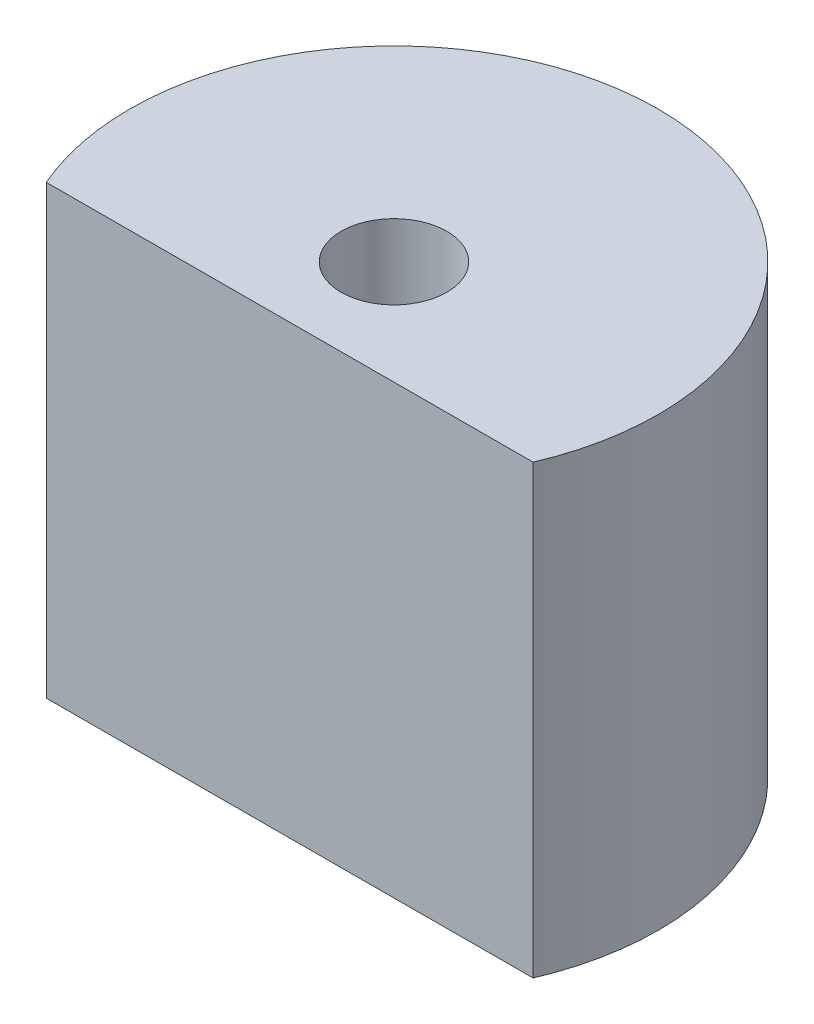
from build123d import *

# Parameters (mm, degrees)
SKETCH1_R               = 7.9375
SKETCH1_R_2             = 1.5875
BOSS_EXTRUDE1_DEPTH     = 13.4112
CUT_EXTRUDE1_DEPTH      = 18.489085109
CUT_EXTRUDE1_DEPTH_BACK = 18.489085109


with BuildPart() as part:
    # Sketch1 → Boss-Extrude1 (new body)
    with BuildSketch(Plane(origin=(0, 0, 0), x_dir=(1, 0, 0), z_dir=(0, 1, 0))):
        Circle(SKETCH1_R)
        Circle(SKETCH1_R_2, mode=Mode.SUBTRACT)
    extrude(amount=BOSS_EXTRUDE1_DEPTH)

    # Sketch2 → Cut-Extrude1 (cut, two sides: drawn at the far end of the back side and taken through both)
    with BuildSketch(Plane.XZ.offset(-CUT_EXTRUDE1_DEPTH_BACK)):
        Polygon((70.109649749, 2.978295714), (12.581756792, 3.108617484), (-13.072608205, 3.166734027), (-70.600501162, 3.297055797), (-70.339857622, 118.352841711), (70.370293289, 118.034081628), align=None)
    extrude(amount=CUT_EXTRUDE1_DEPTH + CUT_EXTRUDE1_DEPTH_BACK, mode=Mode.SUBTRACT)


solid = part.part
